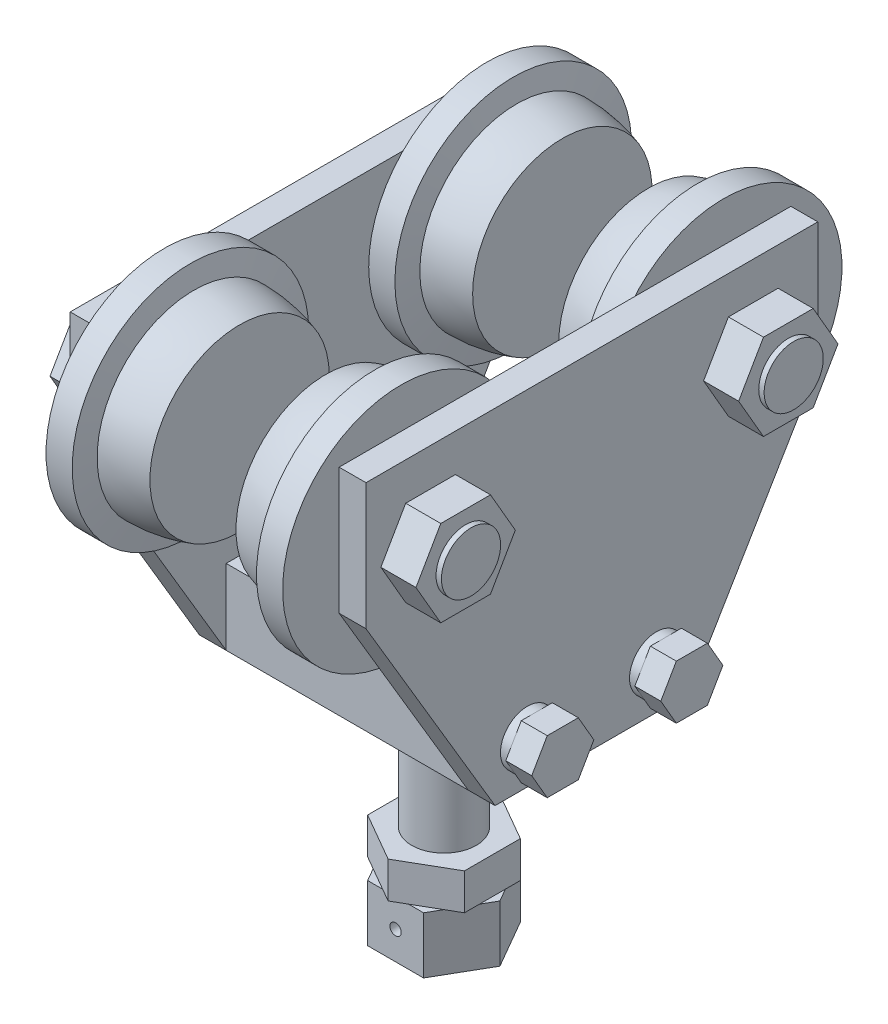
from build123d import *

# Parameters (mm, degrees)
YOKE_CROSS_SECTION_W           = 114.3
YOKE_CROSS_SECTION_H           = 44.45
YOKE_DEPTH                     = 71.4375
SIDEPLATE_DEPTH                = 15.875
WHEEL_PIN_NUT_DEPTH            = 20.701
WHEEL_PIN_PROJECTION_PROFILE_R = 17.4625
WHEEL_PIN_PROJECTION_DEPTH     = 3.175
LOCKNUTS_PROFILE_R             = 15.875
LOCKNUTS_DEPTH                 = 5.5626
SCREWS_DEPTH                   = 15.3416
PROFILE_R                      = 28.575
KING_BOLT_HEAD_DEPTH           = 31.75
DIA_R                          = 19.05
KING_BOLT_DEPTH                = 83.052101
KING_BOLT_JAM_NUT_DEPTH        = 21.43125
KING_BOLT_NUT_DEPTH            = 33.3375
SKETCH5_R                      = 19.05
EXTENDED_KING_BOLT_DEPTH       = 6.35
CHAMFER1_SIZE                  = 2.38125
COTTER_PIN_HOLE_REACH          = 163.925
SKETCH11_R                     = 3.3401
SKETCH13_R                     = 30.1625
SKETCH13_R_2                   = 25.4
SPACER_DEPTH                   = 12.7


with BuildPart() as part:
    # YOKE CROSS SECTION → YOKE (new body)
    with BuildSketch(Plane(origin=(0, 0, 0), x_dir=(0, 0, -1), z_dir=(1, 0, 0))):
        with Locations((0, 22.225)):
            Rectangle(YOKE_CROSS_SECTION_W, YOKE_CROSS_SECTION_H)
    extrude(amount=YOKE_DEPTH)

    # SIDEPLATE PROFILE → SIDEPLATE (add)
    with BuildSketch(Plane(origin=(71.4375, 0, 0), x_dir=(0, 0, -1), z_dir=(1, 0, 0))):
        Polygon((-133.35, 203.2), (-133.35, 128.517771554), (-57.15, 0), (0, 0), (57.15, 0), (133.35, 128.517771554), (133.35, 203.2), align=None)
    extrude(amount=SIDEPLATE_DEPTH)

    # WHEEL PIN NUT PROFILE → WHEEL PIN NUT (add)
    with BuildSketch(Plane(origin=(87.3125, 0, 0), x_dir=(0, 0, -1), z_dir=(1, 0, 0))):
        Polygon((-65.920606325, 155.575), (-80.585303163, 180.975), (-109.914696837, 180.975), (-124.579393675, 155.575), (-109.914696837, 130.175), (-80.585303163, 130.175), align=None)
    wheel_pin_nut = extrude(amount=WHEEL_PIN_NUT_DEPTH)

    # WHEEL PIN PROJECTION PROFILE → WHEEL PIN PROJECTION (add)
    with BuildSketch(Plane(origin=(108.0135, 0, 0), x_dir=(0, 0, -1), z_dir=(1, 0, 0))):
        with Locations((-95.25, 155.575)):
            Circle(WHEEL_PIN_PROJECTION_PROFILE_R)
    wheel_pin_projection = extrude(amount=WHEEL_PIN_PROJECTION_DEPTH)

    # LOCKNUTS PROFILE → LOCKNUTS (add)
    with BuildSketch(Plane(origin=(87.3125, 0, 0), x_dir=(0, 0, -1), z_dir=(1, 0, 0))):
        with Locations(Location((-38.1, 25.4, 0), (0, 0, 180))):  # turned: the seam where the file's is
            Circle(LOCKNUTS_PROFILE_R)
    locknuts = extrude(amount=LOCKNUTS_DEPTH)

    # SCREWS PROFILE → SCREWS (add)
    with BuildSketch(Plane(origin=(92.8751, 0, 0), x_dir=(0, 0, -1), z_dir=(1, 0, 0))):
        Polygon((-19.769128953, 25.4), (-28.934564477, 41.275), (-47.265435523, 41.275), (-56.430871047, 25.4), (-47.265435523, 9.525), (-28.934564477, 9.525), align=None)
    screws = extrude(amount=SCREWS_DEPTH)

    # PROFILE → KING BOLT HEAD (add)
    with BuildSketch(Plane(origin=(0, 44.45, 0), x_dir=(-1, 0, 0), z_dir=(0, 1, 0))):
        with Locations(Location((0, 0, 0), (0, 0, 90))):  # turned: the seam where the file's is
            Circle(PROFILE_R)
    extrude(amount=KING_BOLT_HEAD_DEPTH)

    # Mirror1: WHEEL PIN NUT, WHEEL PIN PROJECTION across plane
    add(wheel_pin_nut.mirror(Plane.XY))
    add(wheel_pin_projection.mirror(Plane.XY))

    # Mirror YOKE SCREWS: LOCKNUTS, SCREWS across plane
    add(locknuts.mirror(Plane.XY))
    add(screws.mirror(Plane.XY))

    # Mirror SIDE 1: part across plane


with BuildPart() as part_1:
    add(part.part)
    add(part.part.mirror(Plane(origin=(0, 0, 0), x_dir=(0, 0, 1), z_dir=(1, 0, 0))))

    # DIA. → KING BOLT (add)
    with BuildSketch(Plane.XZ):
        with Locations(Location((0, 0, 0), (0, 0, 90))):  # turned: the seam where the file's is
            Circle(DIA_R)
    extrude(amount=KING_BOLT_DEPTH)

    # KING BOLT JAN NUT PROFILE → KING BOLT JAM NUT (add)
    with BuildSketch(Plane.XZ.offset(83.052100888)):
        Polygon((0, -32.995567884), (28.575, -16.497783942), (28.575, 16.497783942), (0, 32.995567884), (-28.575, 16.497783942), (-28.575, -16.497783942), align=None)
    extrude(amount=KING_BOLT_JAM_NUT_DEPTH)

    # KING BOLT NUT PROFILE → KING BOLT NUT (add)
    with BuildSketch(Plane.XZ.offset(104.483350888)):
        Polygon((32.995567884, 0), (16.497783942, 28.575), (-16.497783942, 28.575), (-32.995567884, 0), (-16.497783942, -28.575), (16.497783942, -28.575), align=None)
    extrude(amount=KING_BOLT_NUT_DEPTH)

    # Sketch5 → EXTENDED KING BOLT (add)
    with BuildSketch(Plane.XZ.offset(137.820850888)):
        with Locations(Location((0, 0, 0), (0, 0, 90))):  # turned: the seam where the file's is
            Circle(SKETCH5_R)
    extrude(amount=EXTENDED_KING_BOLT_DEPTH)

    # Chamfer1
    chamfer1_edges = [part_1.edges().sort_by_distance(p)[0] for p in [
        (0, -144.170850888, -19.05),
    ]]
    chamfer(chamfer1_edges, length=CHAMFER1_SIZE)

    # Sketch11 → COTTER PIN HOLE (cut, up to next)
    with BuildSketch(Plane(origin=(0, 0, -28.575), x_dir=(-1, 0, 0), z_dir=(0, 0, -1)), mode=Mode.PRIVATE) as cotter_pin_hole_sk1:
        with Locations((0, -121.152100888)):
            Circle(SKETCH11_R)
    cotter_pin_hole_tool1 = extrude(cotter_pin_hole_sk1.sketch, amount=-COTTER_PIN_HOLE_REACH, mode=Mode.PRIVATE) & part_1.part
    add(cotter_pin_hole_tool1.solids().sort_by_distance((0, -121.152101, -28.575))[0], mode=Mode.SUBTRACT)

    # Sketch12 → WHEEL (revolve)
    with BuildSketch(Plane.XY.offset(95.25), mode=Mode.PRIVATE) as wheel_sk:
        with BuildLine():
            Line((25.4, 155.575), (25.4, 208.529691982))
            ThreePointArc((25.4, 208.529691982), (38.731679212, 211.669911968), (52.3875, 212.725))
            Line((52.3875, 212.725), (54.398982392, 225.425))
            Line((54.398982392, 225.425), (69.85, 225.425))
            Line((69.85, 225.425), (69.85, 179.3875))
            Line((69.85, 179.3875), (71.4375, 179.3875))
            Line((71.4375, 179.3875), (71.4375, 155.575))
            Line((71.4375, 155.575), (25.4, 155.575))
        make_face()
    wheel = revolve(wheel_sk.sketch.rotate(Axis((111.1885, 155.575, 95.25), (-1, 0, 0)), 90), axis=Axis((111.1885, 155.575, 95.25), (-1, 0, 0)))  # turned: the seam where the file's is

    # Mirror2: WHEEL across plane
    add(wheel.mirror(Plane.XY))

    # Mirror3: WHEEL across plane
    add(wheel.mirror(Plane(origin=(0, 0, 0), x_dir=(0, 0, 1), z_dir=(1, 0, 0))))

    # Mirror3 copy 1 sketch → Mirror3 copy 1 (revolve)
    with BuildSketch(Plane(origin=(0, 0, -95.25), x_dir=(-1, 0, 0), z_dir=(0, 0, -1))):
        with BuildLine():
            Line((25.4, 155.575), (25.4, 208.529691982))
            ThreePointArc((25.4, 208.529691982), (38.731679212, 211.669911968), (52.3875, 212.725))
            Line((52.3875, 212.725), (54.398982392, 225.425))
            Line((54.398982392, 225.425), (69.85, 225.425))
            Line((69.85, 225.425), (69.85, 179.3875))
            Line((69.85, 179.3875), (71.4375, 179.3875))
            Line((71.4375, 179.3875), (71.4375, 155.575))
            Line((71.4375, 155.575), (25.4, 155.575))
        make_face()
    revolve(axis=Axis((-111.1885, 155.575, -95.25), (1, 0, 0)))

    # Sketch13 → SPACER (add)
    with BuildSketch(Plane.XZ):
        with Locations(Location((0, 0, 0), (0, 0, 90))):  # turned: the seam where the file's is
            Circle(SKETCH13_R)
        with Locations(Location((0, 0, 0), (0, 0, 270))):  # turned: the seam where the file's is
            Circle(SKETCH13_R_2, mode=Mode.SUBTRACT)
    extrude(amount=SPACER_DEPTH)


solid = part_1.part
